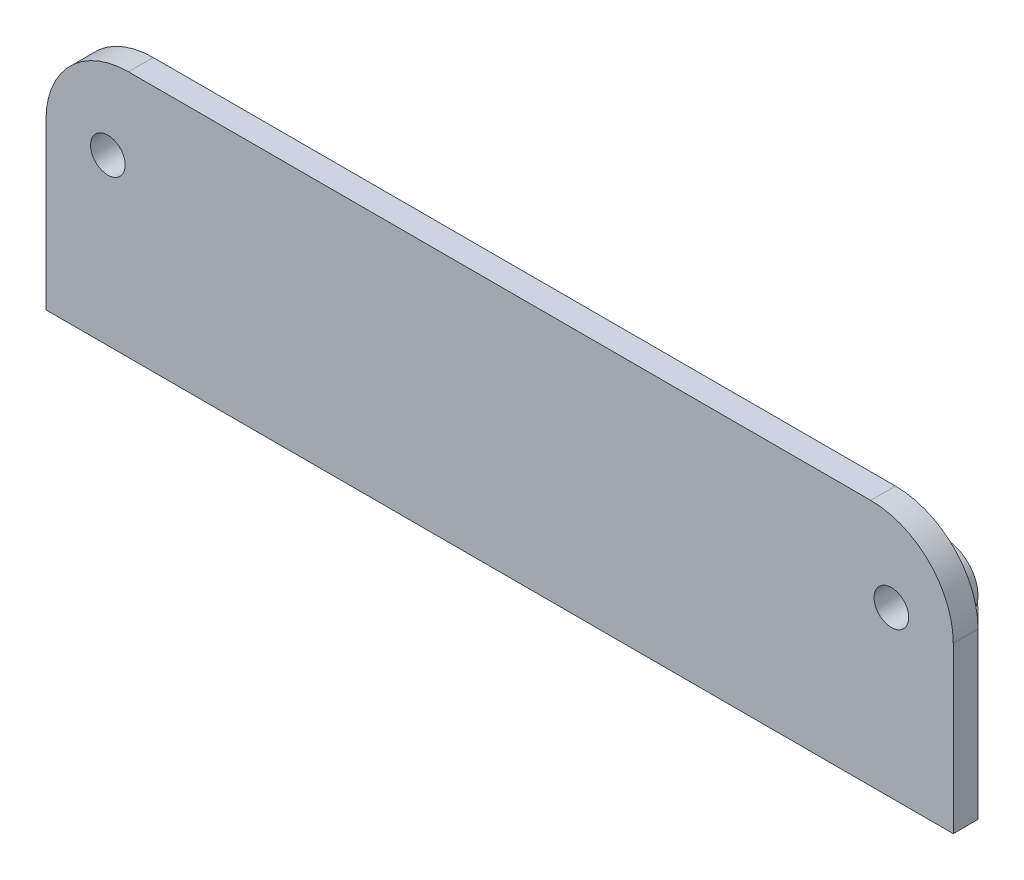
from build123d import *

# Parameters (mm, degrees)
SKETCH1_W            = 110
SKETCH1_H            = 30
SKETCH1_R            = 2.25
EXTRUDE_1_DEPTH      = 5
SKETCH_1_W           = 110
SKETCH_1_H           = 30
SKETCH_1_R           = 2.1
EXTRUDE_2_DEPTH      = 3
FILLET_2_R           = 10
CHAMFER1_SIZE        = 30
EXTRUDE_3_DEPTH      = 38
EXTRUDE_3_DEPTH_BACK = 38
SKETCH_3_W           = 12
SKETCH_3_H           = 15
CUT_EXTRUDE_1_DEPTH  = 26
SKETCH3_R            = 4
SKETCH3_R_2          = 2.1
BOSS_EXTRUDE1_DEPTH  = 3.5
SKETCH4_W            = 114.569016578
SKETCH4_H            = 20
CUT_EXTRUDE1_DEPTH   = 6
FILLET1_R            = 10


with BuildPart() as part:
    # Sketch1 → Бобышка-Вытянуть1 (new body)
    with BuildSketch(Plane(origin=(0, 0, 0), x_dir=(1, 0, 0), z_dir=(0, 1, 0))):
        Rectangle(SKETCH1_W, SKETCH1_H)
        with Locations((-20, -6)):
            Circle(SKETCH1_R, mode=Mode.SUBTRACT)
        with Locations((20, -6)):
            Circle(SKETCH1_R, mode=Mode.SUBTRACT)
    extrude(amount=EXTRUDE_1_DEPTH)

    # Эскиз1 → Бобышка-Вытянуть2 (add)
    with BuildSketch(Plane.XY.offset(15)):
        with Locations((0, 15)):
            Rectangle(SKETCH_1_W, SKETCH_1_H)
        with Locations((-47.5, 20)):
            Circle(SKETCH_1_R, mode=Mode.SUBTRACT)
        with Locations((47.5, 20)):
            Circle(SKETCH_1_R, mode=Mode.SUBTRACT)
    extrude(amount=EXTRUDE_2_DEPTH)

    # Скругление2
    fillet_2_edges = [part.edges().sort_by_distance(p)[0] for p in [
        (-55, 30, 16.5),
        (55, 30, 16.5),
    ]]
    fillet(fillet_2_edges, radius=FILLET_2_R)

    # Chamfer1
    chamfer1_edges = [part.edges().sort_by_distance(p)[0] for p in [
        (-55, 2.5, -15),
        (55, 2.5, -15),
    ]]
    chamfer(chamfer1_edges, length=CHAMFER1_SIZE)

    # Эскиз2 → Бобышка-Вытянуть3 (add, two sides)
    with BuildSketch(Plane(origin=(0, 0, 0), x_dir=(0, 0, -1), z_dir=(1, 0, 0))) as extrude_3_sk:
        Polygon((-15, 30), (0, 5), (-15, 5), align=None)
    extrude(amount=EXTRUDE_3_DEPTH)
    extrude(extrude_3_sk.sketch, amount=-EXTRUDE_3_DEPTH_BACK)

    # Эскиз3 → Вырез-Вытянуть1 (cut, through all)
    with BuildSketch(Plane(origin=(0, 5, 0), x_dir=(1, 0, 0), z_dir=(0, 1, 0))):
        with Locations((20, -7.5)):
            Rectangle(SKETCH_3_W, SKETCH_3_H)
        with Locations((-20, -7.5)):
            Rectangle(SKETCH_3_W, SKETCH_3_H)
        with Locations((0, -7.5)):
            Rectangle(SKETCH_3_W, SKETCH_3_H)
    extrude(amount=CUT_EXTRUDE_1_DEPTH, mode=Mode.SUBTRACT)

    # Sketch3 → Boss-Extrude1 (add)
    with BuildSketch(Plane(origin=(0, 0, 15), x_dir=(-1, 0, 0), z_dir=(0, 0, -1))):
        with Locations((-47.5, 20)):
            Circle(SKETCH3_R)
        with Locations((-47.5, 20)):
            Circle(SKETCH3_R_2, mode=Mode.SUBTRACT)
        with Locations((47.5, 20)):
            Circle(SKETCH3_R)
        with Locations((47.5, 20)):
            Circle(SKETCH3_R_2, mode=Mode.SUBTRACT)
    extrude(amount=BOSS_EXTRUDE1_DEPTH)

    # Sketch4 → Cut-Extrude1 (cut, through all)
    with BuildSketch(Plane(origin=(0, 5, 0), x_dir=(1, 0, 0), z_dir=(0, 1, 0))):
        with Locations((0, 15)):
            Rectangle(SKETCH4_W, SKETCH4_H)
    extrude(amount=-CUT_EXTRUDE1_DEPTH, mode=Mode.SUBTRACT)

    # Fillet1
    fillet1_edges = [part.edges().sort_by_distance(p)[0] for p in [
        (35, 2.5, -5),
        (-35, 2.5, -5),
    ]]
    fillet(fillet1_edges, radius=FILLET1_R)


solid = part.part
